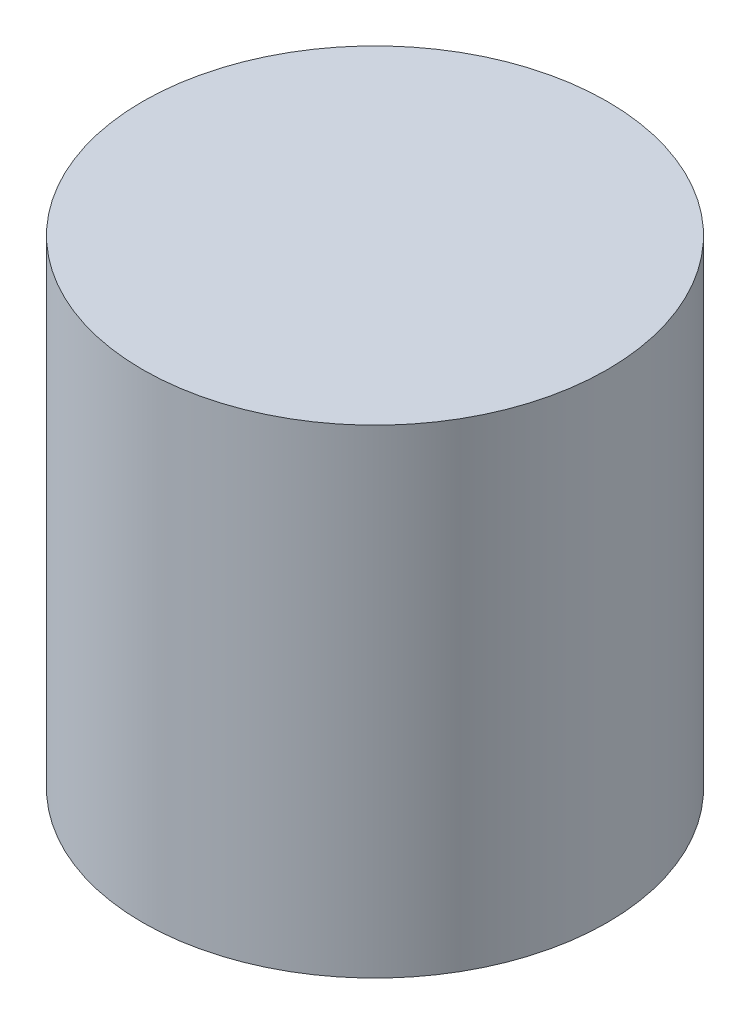
from build123d import *

# Parameters (mm, degrees)
SKETCH1_R           = 49
BOSS_EXTRUDE1_DEPTH = 101


with BuildPart() as part:
    # Sketch1 → Boss-Extrude1 (new body)
    with BuildSketch(Plane(origin=(0, 32.75, 0), x_dir=(1, 0, 0), z_dir=(0, 1, 0))):
        with Locations((287.174494692, 235)):
            Circle(SKETCH1_R)
    extrude(amount=-BOSS_EXTRUDE1_DEPTH)


solid = part.part
